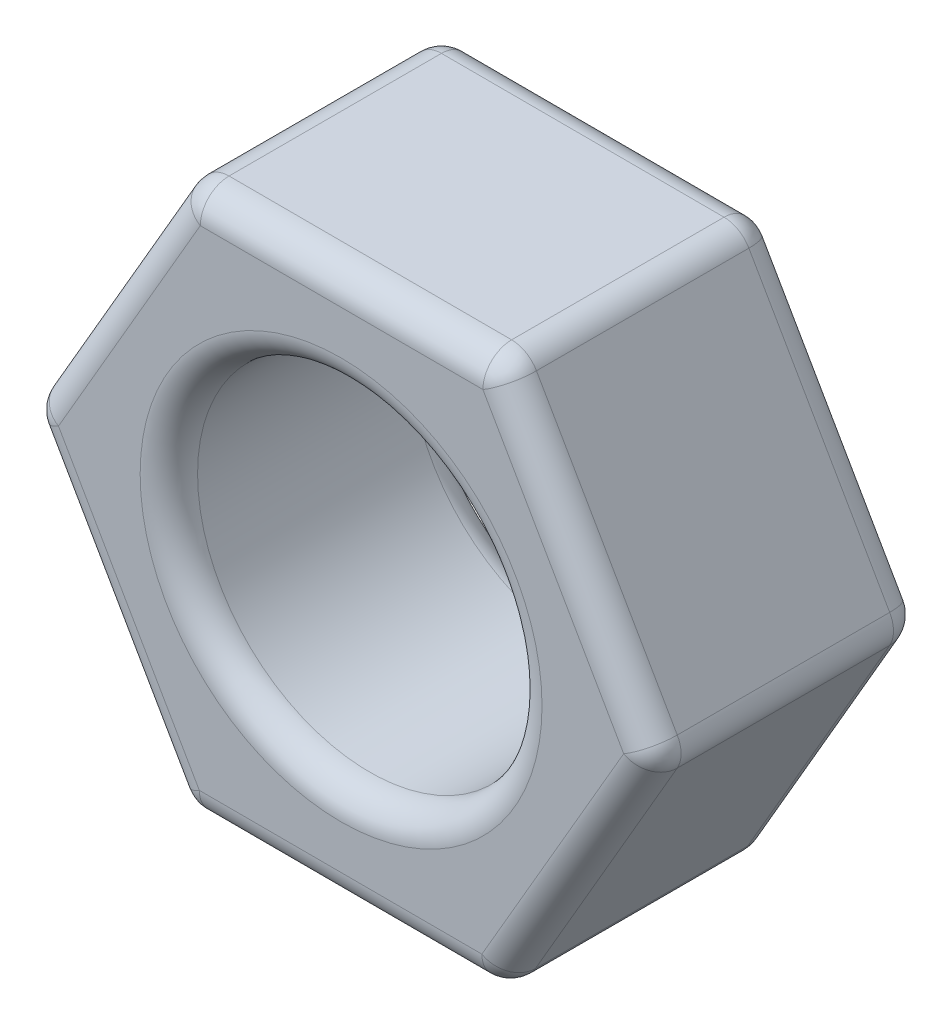
from build123d import *

# Parameters (mm, degrees)
SKETCH1_R           = 3
BOSS_EXTRUDE1_DEPTH = 4.7
FILLET1_R           = 0.5


with BuildPart() as part:
    # Sketch1 → Boss-Extrude1 (new body)
    with BuildSketch(Plane.XY):
        Polygon((-2.740345561, 4.768700683), (-5.499988715, 0.011141471), (-2.759643154, -4.757559213), (2.740345561, -4.768700683), (5.499988715, -0.011141471), (2.759643154, 4.757559213), align=None)
        Circle(SKETCH1_R, mode=Mode.SUBTRACT)
    extrude(amount=BOSS_EXTRUDE1_DEPTH)

    # Fillet1
    fillet1_edges = [part.edges().sort_by_distance(p)[0] for p in [
        (-4.129815935, -2.373208871, 4.7),
        (2.759643154, 4.757559213, 2.35),
        (5.499988715, -0.011141471, 2.35),
        (2.740345561, -4.768700683, 2.35),
        (-2.759643154, -4.757559213, 2.35),
        (-5.499988715, 0.011141471, 2.35),
        (-2.740345561, 4.768700683, 2.35),
        (-0.009648797, -4.763129948, 4.7),
        (4.120167138, -2.389921077, 4.7),
        (-3, 0, 0),
        (-3, 0, 4.7),
        (4.129815935, 2.373208871, 4.7),
        (0.009648797, 4.763129948, 4.7),
        (4.129815935, 2.373208871, 0),
        (4.120167138, -2.389921077, 0),
        (-0.009648797, -4.763129948, 0),
        (-4.120167138, 2.389921077, 4.7),
        (-4.129815935, -2.373208871, 0),
        (-4.120167138, 2.389921077, 0),
        (0.009648797, 4.763129948, 0),
    ]]
    fillet(fillet1_edges, radius=FILLET1_R)


solid = part.part
